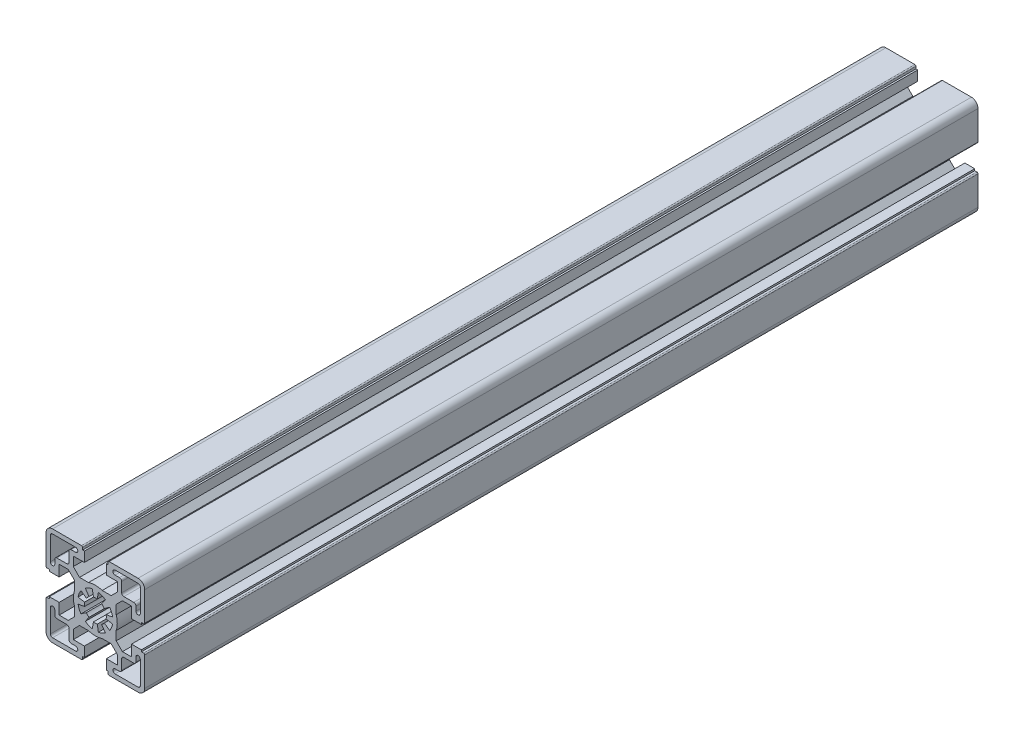
from build123d import *

# Parameters (mm, degrees)
BASE_EXTRUDE_DEPTH = 380


with BuildPart() as part:
    # Sketch1 → Base-Extrude (new body)
    with BuildSketch(Plane.XY):
        with BuildLine():
            Line((-4.99999574, -16.499883971), (-4.99999574, -20.99990968))
            Line((-4.99999574, -20.99990968), (-5.80004044, -20.99990968))
            Line((-5.80004044, -20.99990968), (-5.80004044, -21.999970054))
            ThreePointArc((-5.80004044, -21.999970054), (-5.946487232, -22.353523887), (-6.300041066, -22.49997068))
            Line((-6.300041066, -22.49997068), (-19.500014911, -22.49997068))
            ThreePointArc((-19.500014911, -22.49997068), (-21.62133367, -21.62129168), (-22.50001267, -19.499972921))
            Line((-22.50001267, -19.499972921), (-22.50001267, -6.299929564))
            ThreePointArc((-22.50001267, -6.299929564), (-22.353566213, -5.946376541), (-22.00001319, -5.799930084))
            Line((-22.00001319, -5.799930084), (-21.000012806, -5.799930084))
            Line((-21.000012806, -5.799930084), (-21.000012806, -4.999940084))
            Line((-21.000012806, -4.999940084), (-16.500012806, -4.999940084))
            Line((-16.500012806, -4.999940084), (-16.500012806, -10.049940084))
            Line((-16.500012806, -10.049940084), (-12.342923806, -10.049940084))
            Line((-12.342923806, -10.049940084), (-9.499953806, -7.206970084))
            Line((-9.499953806, -7.206970084), (-9.499953806, -3.122617084))
            ThreePointArc((-9.499953806, -3.122617084), (-10.000013376, 6.1916e-05), (-9.499953806, 3.122740916))
            Line((-9.499953806, 3.122740916), (-9.499953806, 7.206970084))
            Line((-9.499953806, 7.206970084), (-12.342923806, 10.049940084))
            Line((-12.342923806, 10.049940084), (-16.500012806, 10.049940084))
            Line((-16.500012806, 10.049940084), (-16.500012806, 4.999940084))
            Line((-16.500012806, 4.999940084), (-21.000012806, 4.999940084))
            Line((-21.000012806, 4.999940084), (-21.000012806, 5.799930084))
            Line((-21.000012806, 5.799930084), (-22.00001319, 5.799930084))
            ThreePointArc((-22.00001319, 5.799930084), (-22.353566213, 5.946376541), (-22.50001267, 6.299929564))
            Line((-22.50001267, 6.299929564), (-22.50001267, 19.499972921))
            ThreePointArc((-22.50001267, 19.499972921), (-21.62133367, 21.62129168), (-19.500014911, 22.49997068))
            Line((-19.500014911, 22.49997068), (-6.299954884, 22.49997068))
            ThreePointArc((-6.299954884, 22.49997068), (-5.946364566, 22.353508775), (-5.799902661, 21.999918456))
            Line((-5.799902661, 21.999918456), (-5.799902661, 20.999918083))
            Line((-5.799902661, 20.999918083), (-4.99999574, 20.999918083))
            Line((-4.99999574, 20.999918083), (-4.99999574, 16.499989166))
            Line((-4.99999574, 16.499989166), (-10.050086009, 16.499989166))
            Line((-10.050086009, 16.499989166), (-10.050086009, 12.342794971))
            Line((-10.050086009, 12.342794971), (-7.207151696, 9.499860659))
            Line((-7.207151696, 9.499860659), (-3.122798696, 9.499860659))
            ThreePointArc((-3.122798696, 9.499860659), (-0.000120196, 9.999920064), (3.122558304, 9.499860659))
            Line((3.122558304, 9.499860659), (7.206958901, 9.499860659))
            Line((7.206958901, 9.499860659), (10.049884116, 12.342787875))
            Line((10.049884116, 12.342787875), (10.049884116, 16.499989166))
            Line((10.049884116, 16.499989166), (4.99999574, 16.499989166))
            Line((4.99999574, 16.499989166), (4.99999574, 20.999963909))
            Line((4.99999574, 20.999963909), (5.799902661, 20.999963909))
            Line((5.799902661, 20.999963909), (5.799902661, 21.999918456))
            ThreePointArc((5.799902661, 21.999918456), (5.946364566, 22.353508775), (6.299954884, 22.49997068))
            Line((6.299954884, 22.49997068), (19.500081571, 22.49997068))
            ThreePointArc((19.500081571, 22.49997068), (21.62140033, 21.62129168), (22.50007933, 19.499972921))
            Line((22.50007933, 19.499972921), (22.50007933, 6.299877709))
            ThreePointArc((22.50007933, 6.299877709), (22.35363283, 5.946324583), (22.000079704, 5.799878083))
            Line((22.000079704, 5.799878083), (20.999995421, 5.799878083))
            Line((20.999995421, 5.799878083), (20.999995421, 4.999941084))
            Line((20.999995421, 4.999941084), (16.499983596, 4.999941084))
            Line((16.499983596, 4.999941084), (16.499983596, 10.049940084))
            Line((16.499983596, 10.049940084), (12.342894596, 10.049940084))
            Line((12.342894596, 10.049940084), (9.499922596, 7.206970084))
            Line((9.499922596, 7.206970084), (9.499922596, 3.122735916))
            ThreePointArc((9.499922596, 3.122735916), (9.999982165, 5.6916e-05), (9.499922596, -3.122622084))
            Line((9.499922596, -3.122622084), (9.499922596, -7.206970084))
            Line((9.499922596, -7.206970084), (12.342894596, -10.049940084))
            Line((12.342894596, -10.049940084), (16.499983596, -10.049940084))
            Line((16.499983596, -10.049940084), (16.499983596, -4.999941084))
            Line((16.499983596, -4.999941084), (20.999995421, -4.999941084))
            Line((20.999995421, -4.999941084), (20.999995421, -5.799878083))
            Line((20.999995421, -5.799878083), (22.000079704, -5.799878083))
            ThreePointArc((22.000079704, -5.799878083), (22.35363283, -5.946324583), (22.50007933, -6.299877709))
            Line((22.50007933, -6.299877709), (22.50007933, -19.499973421))
            ThreePointArc((22.50007933, -19.499973421), (21.621400476, -21.621291826), (19.500082071, -22.49997068))
            Line((19.500082071, -22.49997068), (6.300041066, -22.49997068))
            ThreePointArc((6.300041066, -22.49997068), (5.946487232, -22.353523887), (5.80004044, -21.999970054))
            Line((5.80004044, -21.999970054), (5.80004044, -20.99990968))
            Line((5.80004044, -20.99990968), (4.99999574, -20.99990968))
            Line((4.99999574, -20.99990968), (4.99999574, -16.499883971))
            Line((4.99999574, -16.499883971), (10.049884116, -16.499883971))
            Line((10.049884116, -16.499883971), (10.049884116, -12.342787875))
            Line((10.049884116, -12.342787875), (7.206933602, -9.49983536))
            Line((7.206933602, -9.49983536), (3.122579602, -9.49983536))
            ThreePointArc((3.122579602, -9.49983536), (-9.9398e-05, -9.99989493), (-3.122778398, -9.49983536))
            Line((-3.122778398, -9.49983536), (-7.207126398, -9.49983536))
            Line((-7.207126398, -9.49983536), (-10.050086009, -12.342794971))
            Line((-10.050086009, -12.342794971), (-10.050086009, -16.499883971))
            Line((-10.050086009, -16.499883971), (-4.99999574, -16.499883971))
        make_face()
        with BuildLine():
            Line((0.868239441, 4.924019626), (1.389186106, 7.878448412))
            ThreePointArc((1.389186106, 7.878448412), (3.061471579, 7.391020172), (4.588617704, 6.553195784))
            Line((4.588617704, 6.553195784), (2.867879873, 4.095738521))
            ThreePointArc((2.867879873, 4.095738521), (3.535523556, 3.535517244), (4.095743641, 2.867872561))
            Line((4.095743641, 2.867872561), (6.553203976, 4.588606005))
            ThreePointArc((6.553203976, 4.588606005), (7.391023332, 3.061463952), (7.878448799, 1.389183909))
            Line((7.878448799, 1.389183909), (4.924019868, 0.868238068))
            ThreePointArc((4.924019868, 0.868238068), (4.9999809, 7.81e-07), (4.924020139, -0.868236529))
            Line((4.924020139, -0.868236529), (7.878449234, -1.389181447))
            ThreePointArc((7.878449234, -1.389181447), (7.391025132, -3.061459606), (6.553207937, -4.588600349))
            Line((6.553207937, -4.588600349), (4.095746117, -2.867869026))
            ThreePointArc((4.095746117, -2.867869026), (3.535522832, -3.535517968), (2.86787466, -4.095742171))
            Line((2.86787466, -4.095742171), (4.588609364, -6.553201624))
            ThreePointArc((4.588609364, -6.553201624), (3.061466598, -7.391022236), (1.389185513, -7.878448517))
            Line((1.389185513, -7.878448517), (0.868239071, -4.924019691))
            ThreePointArc((0.868239071, -4.924019691), (8.15e-07, -4.9999809), (-0.868237465, -4.924019974))
            Line((-0.868237465, -4.924019974), (-1.389182943, -7.87844897))
            ThreePointArc((-1.389182943, -7.87844897), (-3.06146423, -7.391023216), (-4.588607303, -6.553203067))
            Line((-4.588607303, -6.553203067), (-2.867873372, -4.095743073))
            ThreePointArc((-2.867873372, -4.095743073), (-3.535520061, -3.535520739), (-4.095742523, -2.867874158))
            Line((-4.095742523, -2.867874158), (-6.553202186, -4.588608561))
            ThreePointArc((-6.553202186, -4.588608561), (-7.391024272, -3.061461681), (-7.878450195, -1.389175997))
            Line((-7.878450195, -1.389175997), (-4.92402074, -0.868233124))
            ThreePointArc((-4.92402074, -0.868233124), (-4.9999809, 1.729e-06), (-4.924020139, 0.868236529))
            Line((-4.924020139, 0.868236529), (-7.878449234, 1.389181447))
            ThreePointArc((-7.878449234, 1.389181447), (-7.391023494, 3.061463561), (-6.553203027, 4.588607361))
            Line((-6.553203027, 4.588607361), (-4.095743048, 2.867873408))
            ThreePointArc((-4.095743048, 2.867873408), (-3.535525782, 3.535515019), (-2.867885877, 4.095734317))
            Line((-2.867885877, 4.095734317), (-4.588627311, 6.553189058))
            ThreePointArc((-4.588627311, 6.553189058), (-3.061465289, 7.391022778), (-1.389161147, 7.878452813))
            Line((-1.389161147, 7.878452813), (-0.868223842, 4.924022376))
            ThreePointArc((-0.868223842, 4.924022376), (7.92e-06, 4.9999809), (0.868239441, 4.924019626))
        make_face(mode=Mode.SUBTRACT)
        with BuildLine():
            Line((-17.500118733, -12.000017917), (-13.000117238, -12.000017917))
            ThreePointArc((-13.000117238, -12.000017917), (-12.293010985, -12.292910917), (-12.000117985, -13.00001717))
            Line((-12.000117985, -13.00001717), (-12.000117985, -17.49992083))
            ThreePointArc((-12.000117985, -17.49992083), (-11.707224985, -18.207027083), (-11.000118733, -18.499920083))
            Line((-11.000118733, -18.499920083), (-9.000117985, -18.499920083))
            ThreePointArc((-9.000117985, -18.499920083), (-8.000069068, -19.499969), (-9.000117985, -20.500017917))
            Line((-9.000117985, -20.500017917), (-19.500118733, -20.500017917))
            ThreePointArc((-19.500118733, -20.500017917), (-20.207224985, -20.207124917), (-20.500117985, -19.500018664))
            Line((-20.500117985, -19.500018664), (-20.500117985, -8.999920083))
            ThreePointArc((-20.500117985, -8.999920083), (-19.500117985, -7.999920083), (-18.500117985, -8.999920083))
            Line((-18.500117985, -8.999920083), (-18.500117985, -11.000018664))
            ThreePointArc((-18.500117985, -11.000018664), (-18.207224985, -11.707124917), (-17.500118733, -12.000017917))
        make_face(mode=Mode.SUBTRACT)
        with BuildLine():
            Line((13.000003267, -12.000017917), (17.500004762, -12.000017917))
            ThreePointArc((17.500004762, -12.000017917), (18.207111015, -11.707124917), (18.500004015, -11.000018664))
            Line((18.500004015, -11.000018664), (18.500004015, -9.000115751))
            ThreePointArc((18.500004015, -9.000115751), (19.500004015, -8.000115751), (20.500004015, -9.000115751))
            Line((20.500004015, -9.000115751), (20.500004015, -19.500018664))
            ThreePointArc((20.500004015, -19.500018664), (20.207111015, -20.207124917), (19.500004762, -20.500017917))
            Line((19.500004762, -20.500017917), (9.000004015, -20.500017917))
            ThreePointArc((9.000004015, -20.500017917), (7.999955097, -19.499969), (9.000004015, -18.499920083))
            Line((9.000004015, -18.499920083), (11.000004762, -18.499920083))
            ThreePointArc((11.000004762, -18.499920083), (11.707111015, -18.207027083), (12.000004015, -17.49992083))
            Line((12.000004015, -17.49992083), (12.000004015, -13.00001717))
            ThreePointArc((12.000004015, -13.00001717), (12.292897015, -12.292910917), (13.000003267, -12.000017917))
        make_face(mode=Mode.SUBTRACT)
        with BuildLine():
            Line((-17.500118733, 12.000017917), (-13.000117238, 12.000017917))
            ThreePointArc((-13.000117238, 12.000017917), (-12.293010985, 12.292910917), (-12.000117985, 13.00001717))
            Line((-12.000117985, 13.00001717), (-12.000117985, 17.49992083))
            ThreePointArc((-12.000117985, 17.49992083), (-11.707224985, 18.207027083), (-11.000118733, 18.499920083))
            Line((-11.000118733, 18.499920083), (-9.000117985, 18.499920083))
            ThreePointArc((-9.000117985, 18.499920083), (-8.000069068, 19.499969), (-9.000117985, 20.500017917))
            Line((-9.000117985, 20.500017917), (-19.500118733, 20.500017917))
            ThreePointArc((-19.500118733, 20.500017917), (-20.207224985, 20.207124917), (-20.500117985, 19.500018664))
            Line((-20.500117985, 19.500018664), (-20.500117985, 8.999920083))
            ThreePointArc((-20.500117985, 8.999920083), (-19.500117985, 7.999920083), (-18.500117985, 8.999920083))
            Line((-18.500117985, 8.999920083), (-18.500117985, 11.000018664))
            ThreePointArc((-18.500117985, 11.000018664), (-18.207224985, 11.707124917), (-17.500118733, 12.000017917))
        make_face(mode=Mode.SUBTRACT)
        with BuildLine():
            Line((13.000003267, 12.000017917), (17.500004762, 12.000017917))
            ThreePointArc((17.500004762, 12.000017917), (18.207111015, 11.707124917), (18.500004015, 11.000018664))
            Line((18.500004015, 11.000018664), (18.500004015, 9.000115751))
            ThreePointArc((18.500004015, 9.000115751), (19.500004015, 8.000115751), (20.500004015, 9.000115751))
            Line((20.500004015, 9.000115751), (20.500004015, 19.500018664))
            ThreePointArc((20.500004015, 19.500018664), (20.207111015, 20.207124917), (19.500004762, 20.500017917))
            Line((19.500004762, 20.500017917), (9.000004015, 20.500017917))
            ThreePointArc((9.000004015, 20.500017917), (7.999955097, 19.499969), (9.000004015, 18.499920083))
            Line((9.000004015, 18.499920083), (11.000004762, 18.499920083))
            ThreePointArc((11.000004762, 18.499920083), (11.707111015, 18.207027083), (12.000004015, 17.49992083))
            Line((12.000004015, 17.49992083), (12.000004015, 13.00001717))
            ThreePointArc((12.000004015, 13.00001717), (12.292897015, 12.292910917), (13.000003267, 12.000017917))
        make_face(mode=Mode.SUBTRACT)
    extrude(amount=BASE_EXTRUDE_DEPTH)


solid = part.part
